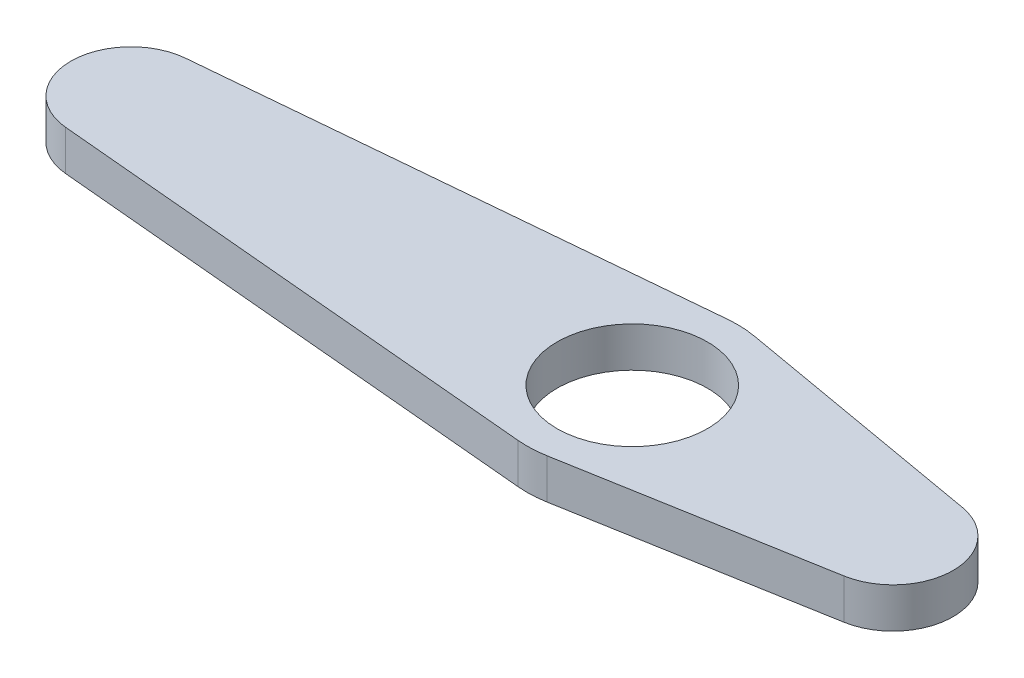
from build123d import *

# Parameters (mm, degrees)
SKETCH1_R           = 3.75
BOSS_EXTRUDE1_DEPTH = 1


with BuildPart() as part:
    # Sketch1 → Boss-Extrude1 (new body, symmetric)
    with BuildSketch(Plane(origin=(0, 0, 0), x_dir=(1, 0, 0), z_dir=(0, 1, 0))):
        with BuildLine():
            Line((-25.27, -2.987825296), (-0.4725, -5.228694268))
            ThreePointArc((-0.4725, -5.228694268), (0.219991794, -5.245388795), (0.908653846, -5.170768626))
            Line((0.908653846, -5.170768626), (13.519230769, -2.954724929))
            ThreePointArc((13.519230769, -2.954724929), (16, 0), (13.519230769, 2.954724929))
            Line((13.519230769, 2.954724929), (0.908653846, 5.170768626))
            ThreePointArc((0.908653846, 5.170768626), (0.219991794, 5.245388795), (-0.4725, 5.228694268))
            Line((-0.4725, 5.228694268), (-25.27, 2.987825296))
            ThreePointArc((-25.27, 2.987825296), (-28, 0), (-25.27, -2.987825296))
        make_face()
        Circle(SKETCH1_R, mode=Mode.SUBTRACT)
    extrude(amount=BOSS_EXTRUDE1_DEPTH, both=True)


solid = part.part
